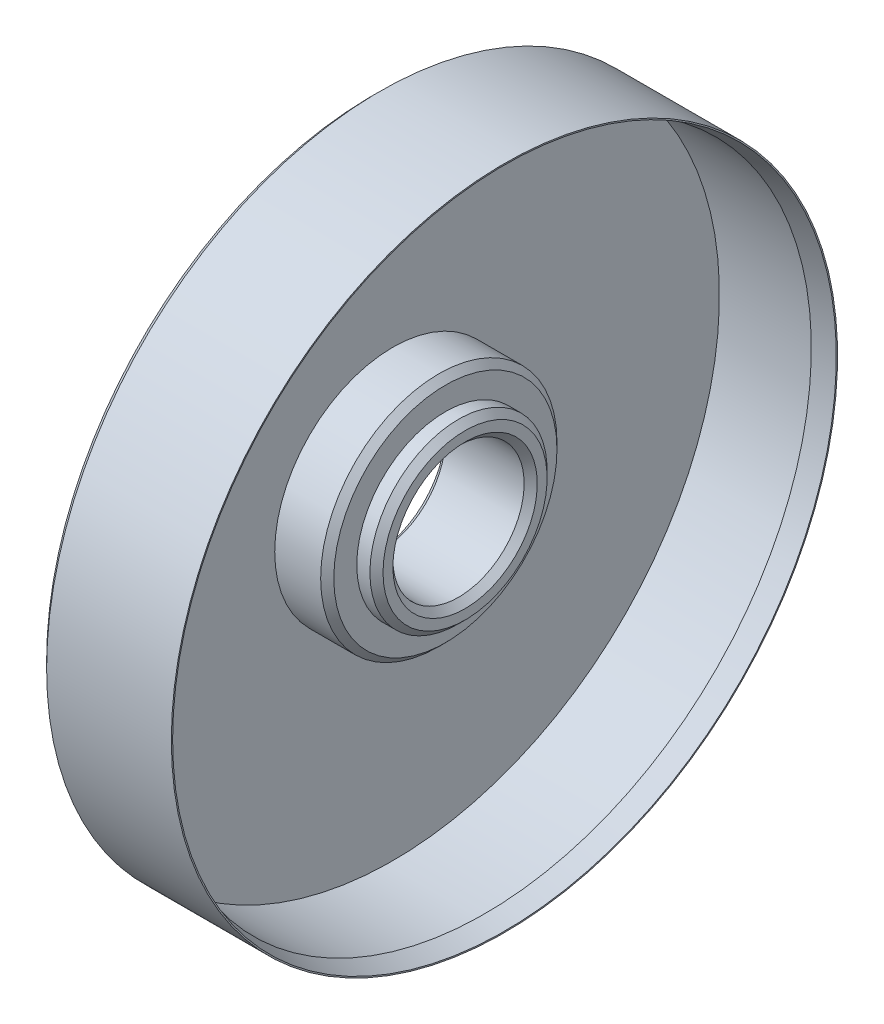
from build123d import *


with BuildPart() as part:
    # Эскиз1 → Повернуть1 (revolve)
    with BuildSketch(Plane.XY):
        Polygon((0, 11), (0, 49.75), (1, 50.75), (20, 50.75), (20, 50.553847577), (17, 49.75), (3, 49.75), (3, 18), (10, 18), (11, 17), (11, 13.5), (13, 13.5), (14, 12.5), (14, 11), (13, 10), (1, 10), align=None)
    revolve(axis=Axis((0, 0, 0), (1, 0, 0)))


solid = part.part
